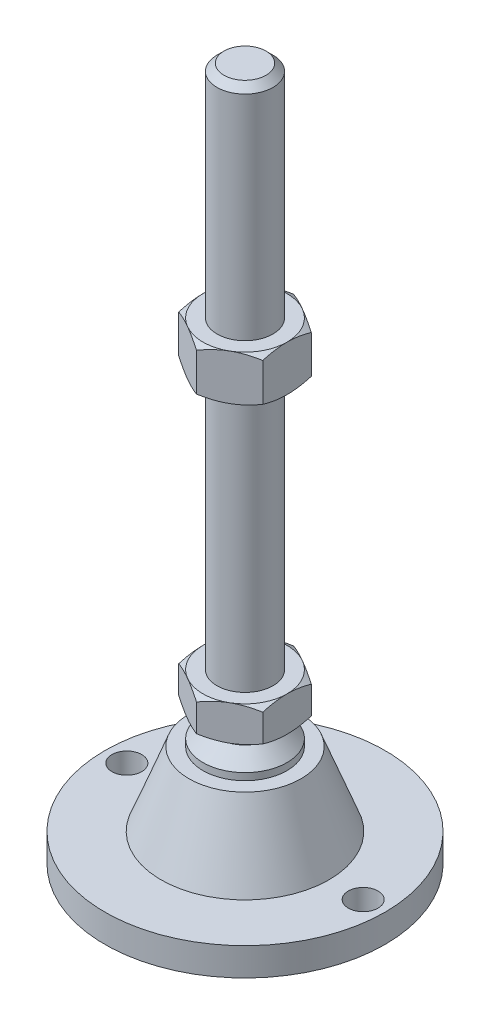
from build123d import *

# Parameters (mm, degrees)
EXTRUDE_1_DEPTH     = 10
EXTRUDE_2_DEPTH     = 13
SKETCH_5_R          = 4.25
CUT_EXTRUDE_1_DEPTH = 9


with BuildPart() as part:
    # Эскиз1 → Повернуть1 (revolve)
    with BuildSketch(Plane.XY, mode=Mode.PRIVATE) as revolve_1_sk:
        Polygon((0, 0), (-40, 0), (-40, 8), (-24, 8), (-16, 29), (-12, 29), (-12, 31), (-8, 35), (-8, 38), (-8, 48), (-8, 196), (-6, 198), (0, 198), align=None)
    revolve(revolve_1_sk.sketch.rotate(Axis((0, 0, 0), (0, 1, 0)), 180), axis=Axis((0, 0, 0), (0, 1, 0)))  # turned: the seam where the file's is

    # Эскиз2 → Бобышка-Вытянуть1 (add)
    with BuildSketch(Plane(origin=(0, 38, 0), x_dir=(1, 0, 0), z_dir=(0, 1, 0))):
        Polygon((0, 13.856406461), (-12, 6.92820323), (-12, -6.92820323), (0, -13.856406461), (12, -6.92820323), (12, 6.92820323), align=None)
    extrude(amount=EXTRUDE_1_DEPTH)

    # Эскиз3 → Бобышка-Вытянуть2 (add)
    with BuildSketch(Plane(origin=(0, 122, 0), x_dir=(1, 0, 0), z_dir=(0, 1, 0))):
        Polygon((12, 6.92820323), (0, 13.856406461), (-12, 6.92820323), (-12, -6.92820323), (0, -13.856406461), (12, -6.92820323), align=None)
    extrude(amount=EXTRUDE_2_DEPTH)

    # Эскиз4 → Вырез-Повернуть2 (revolve, cut)
    with BuildSketch(Plane.XY, mode=Mode.PRIVATE) as cut_revolve_2_sk:
        Polygon((-23.258330249, 135), (-12, 135), (-23.258330249, 128.5), align=None)
        Polygon((-23.258330249, 122), (-23.258330249, 128.5), (-12, 122), align=None)
        Polygon((-20.660254038, 48), (-20.660254038, 43), (-12, 48), align=None)
        Polygon((-20.660254038, 43), (-20.660254038, 38), (-12, 38), align=None)
    revolve(cut_revolve_2_sk.sketch.rotate(Axis((0, 198, 0), (0, -1, 0)), 180), axis=Axis((0, 198, 0), (0, -1, 0)), mode=Mode.SUBTRACT)  # turned: the seam where the file's is

    # Эскиз5 → Вырез-Вытянуть1 (cut, through all)
    with BuildSketch(Plane(origin=(0, 8, 0), x_dir=(1, 0, 0), z_dir=(0, 1, 0))):
        with Locations(Location((-33.75, 0, 0), (0, 0, 180))):  # turned: the seam where the file's is
            Circle(SKETCH_5_R)
        with Locations(Location((33.75, 0, 0), (0, 0, 180))):  # turned: the seam where the file's is
            Circle(SKETCH_5_R)
    extrude(amount=-CUT_EXTRUDE_1_DEPTH, mode=Mode.SUBTRACT)


solid = part.part
